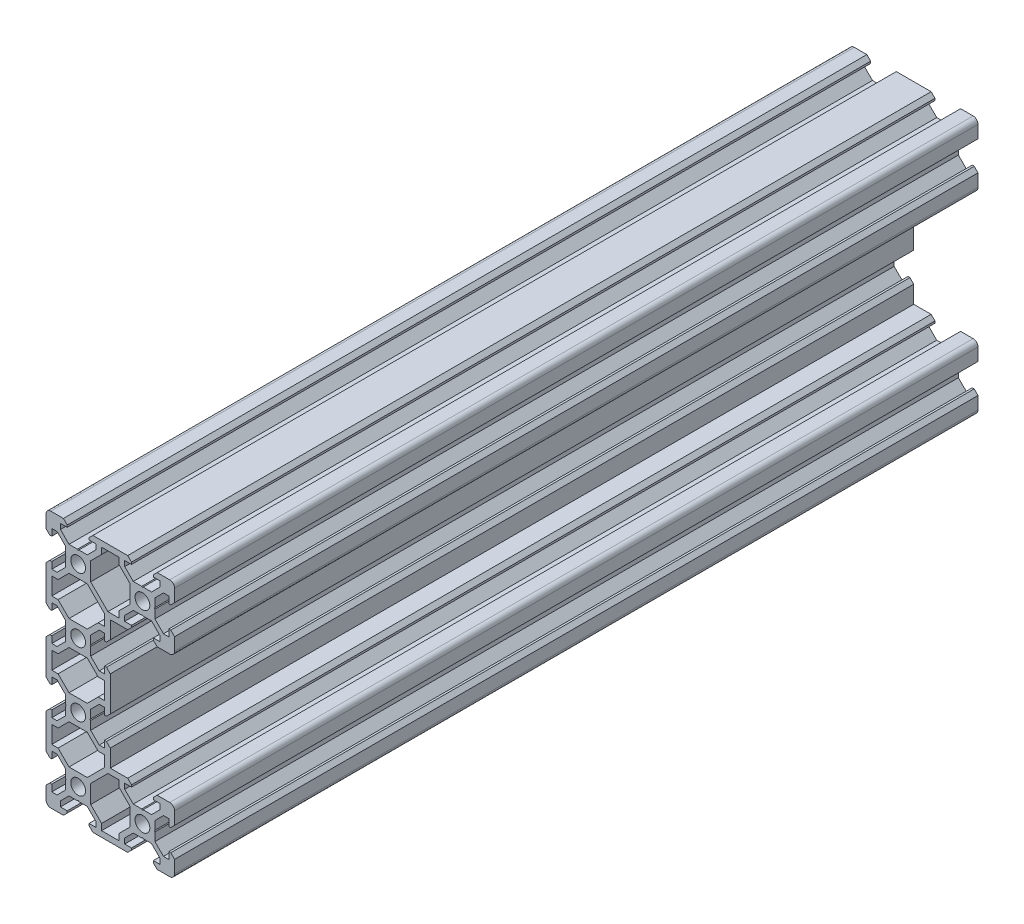
from build123d import *

# Parameters (mm, degrees)
SKETCH1_R           = 2.3
BOSS_EXTRUDE1_DEPTH = 250


with BuildPart() as part:
    # Sketch1 → Boss-Extrude1 (new body)
    with BuildSketch(Plane.XY):
        with BuildLine():
            Line((-20, -34.58), (-20, -38.5))
            ThreePointArc((-20, -38.5), (-19.560660172, -39.560660172), (-18.5, -40))
            Line((-18.5, -40), (-14.58, -40))
            Line((-14.58, -40), (-13.395, -38.815))
            Line((-13.395, -38.815), (-13.395, -38.2))
            Line((-13.395, -38.2), (-15.5, -38.2))
            Line((-15.5, -38.2), (-15.5, -36.560660172))
            Line((-15.5, -36.560660172), (-12.839339828, -33.9))
            Line((-12.839339828, -33.9), (-10.21, -33.9))
            Line((-10.21, -33.9), (-10, -33.69))
            Line((-10, -33.69), (-9.79, -33.9))
            Line((-9.79, -33.9), (-7.160660172, -33.9))
            Line((-7.160660172, -33.9), (-4.5, -36.560660172))
            Line((-4.5, -36.560660172), (-4.5, -38.2))
            Line((-4.5, -38.2), (-6.605, -38.2))
            Line((-6.605, -38.2), (-6.605, -38.815))
            Line((-6.605, -38.815), (-5.42, -40))
            Line((-5.42, -40), (5.42, -40))
            Line((5.42, -40), (6.605, -38.815))
            Line((6.605, -38.815), (6.605, -38.2))
            Line((6.605, -38.2), (4.5, -38.2))
            Line((4.5, -38.2), (4.5, -36.560660172))
            Line((4.5, -36.560660172), (7.160660172, -33.9))
            Line((7.160660172, -33.9), (9.79, -33.9))
            Line((9.79, -33.9), (10, -33.69))
            Line((10, -33.69), (10.21, -33.9))
            Line((10.21, -33.9), (12.839339828, -33.9))
            Line((12.839339828, -33.9), (15.5, -36.560660172))
            Line((15.5, -36.560660172), (15.5, -38.2))
            Line((15.5, -38.2), (13.395, -38.2))
            Line((13.395, -38.2), (13.395, -38.815))
            Line((13.395, -38.815), (14.58, -40))
            Line((14.58, -40), (18.5, -40))
            ThreePointArc((18.5, -40), (19.560660172, -39.560660172), (20, -38.5))
            Line((20, -38.5), (20, -34.58))
            Line((20, -34.58), (18.815, -33.395))
            Line((18.815, -33.395), (18.2, -33.395))
            Line((18.2, -33.395), (18.2, -35.5))
            Line((18.2, -35.5), (16.560660172, -35.5))
            Line((16.560660172, -35.5), (13.9, -32.839339828))
            Line((13.9, -32.839339828), (13.9, -30.21))
            Line((13.9, -30.21), (13.69, -30))
            Line((13.69, -30), (13.9, -29.79))
            Line((13.9, -29.79), (13.9, -27.160660172))
            Line((13.9, -27.160660172), (16.560660172, -24.5))
            Line((16.560660172, -24.5), (18.2, -24.5))
            Line((18.2, -24.5), (18.2, -26.605))
            Line((18.2, -26.605), (18.815, -26.605))
            Line((18.815, -26.605), (20, -25.42))
            Line((20, -25.42), (20, -21.5))
            ThreePointArc((20, -21.5), (19.560660172, -20.439339828), (18.5, -20))
            Line((18.5, -20), (14.58, -20))
            Line((14.58, -20), (13.395, -21.185))
            Line((13.395, -21.185), (13.395, -21.8))
            Line((13.395, -21.8), (15.5, -21.8))
            Line((15.5, -21.8), (15.5, -23.439339828))
            Line((15.5, -23.439339828), (12.839339828, -26.1))
            Line((12.839339828, -26.1), (10.21, -26.1))
            Line((10.21, -26.1), (10, -26.31))
            Line((10, -26.31), (9.79, -26.1))
            Line((9.79, -26.1), (7.160660172, -26.1))
            Line((7.160660172, -26.1), (4.5, -23.439339828))
            Line((4.5, -23.439339828), (4.5, -21.8))
            Line((4.5, -21.8), (6.605, -21.8))
            Line((6.605, -21.8), (6.605, -21.185))
            Line((6.605, -21.185), (5.42, -20))
            Line((5.42, -20), (0, -20))
            Line((0, -20), (0, -14.58))
            Line((0, -14.58), (-1.185, -13.395))
            Line((-1.185, -13.395), (-1.8, -13.395))
            Line((-1.8, -13.395), (-1.8, -15.5))
            Line((-1.8, -15.5), (-3.439339828, -15.5))
            Line((-3.439339828, -15.5), (-6.1, -12.839339828))
            Line((-6.1, -12.839339828), (-6.1, -10.21))
            Line((-6.1, -10.21), (-6.31, -10))
            Line((-6.31, -10), (-6.1, -9.79))
            Line((-6.1, -9.79), (-6.1, -7.160660172))
            Line((-6.1, -7.160660172), (-3.439339828, -4.5))
            Line((-3.439339828, -4.5), (-1.8, -4.5))
            Line((-1.8, -4.5), (-1.8, -6.605))
            Line((-1.8, -6.605), (-1.185, -6.605))
            Line((-1.185, -6.605), (0, -5.42))
            Line((0, -5.42), (0, 5.42))
            Line((0, 5.42), (-1.185, 6.605))
            Line((-1.185, 6.605), (-1.8, 6.605))
            Line((-1.8, 6.605), (-1.8, 4.5))
            Line((-1.8, 4.5), (-3.439339828, 4.5))
            Line((-3.439339828, 4.5), (-6.1, 7.160660172))
            Line((-6.1, 7.160660172), (-6.1, 9.79))
            Line((-6.1, 9.79), (-6.31, 10))
            Line((-6.31, 10), (-6.1, 10.21))
            Line((-6.1, 10.21), (-6.1, 12.839339828))
            Line((-6.1, 12.839339828), (-3.439339828, 15.5))
            Line((-3.439339828, 15.5), (-1.8, 15.5))
            Line((-1.8, 15.5), (-1.8, 13.395))
            Line((-1.8, 13.395), (-1.185, 13.395))
            Line((-1.185, 13.395), (0, 14.58))
            Line((0, 14.58), (0, 20))
            Line((0, 20), (5.42, 20))
            Line((5.42, 20), (6.605, 21.185))
            Line((6.605, 21.185), (6.605, 21.8))
            Line((6.605, 21.8), (4.5, 21.8))
            Line((4.5, 21.8), (4.5, 23.439339828))
            Line((4.5, 23.439339828), (7.160660172, 26.1))
            Line((7.160660172, 26.1), (9.79, 26.1))
            Line((9.79, 26.1), (10, 26.31))
            Line((10, 26.31), (10.21, 26.1))
            Line((10.21, 26.1), (12.839339828, 26.1))
            Line((12.839339828, 26.1), (15.5, 23.439339828))
            Line((15.5, 23.439339828), (15.5, 21.8))
            Line((15.5, 21.8), (13.395, 21.8))
            Line((13.395, 21.8), (13.395, 21.185))
            Line((13.395, 21.185), (14.58, 20))
            Line((14.58, 20), (18.5, 20))
            ThreePointArc((18.5, 20), (19.560660172, 20.439339828), (20, 21.5))
            Line((20, 21.5), (20, 25.42))
            Line((20, 25.42), (18.815, 26.605))
            Line((18.815, 26.605), (18.2, 26.605))
            Line((18.2, 26.605), (18.2, 24.5))
            Line((18.2, 24.5), (16.560660172, 24.5))
            Line((16.560660172, 24.5), (13.9, 27.160660172))
            Line((13.9, 27.160660172), (13.9, 29.79))
            Line((13.9, 29.79), (13.69, 30))
            Line((13.69, 30), (13.9, 30.21))
            Line((13.9, 30.21), (13.9, 32.839339828))
            Line((13.9, 32.839339828), (16.560660172, 35.5))
            Line((16.560660172, 35.5), (18.2, 35.5))
            Line((18.2, 35.5), (18.2, 33.395))
            Line((18.2, 33.395), (18.815, 33.395))
            Line((18.815, 33.395), (20, 34.58))
            Line((20, 34.58), (20, 38.5))
            ThreePointArc((20, 38.5), (19.560660172, 39.560660172), (18.5, 40))
            Line((18.5, 40), (14.58, 40))
            Line((14.58, 40), (13.395, 38.815))
            Line((13.395, 38.815), (13.395, 38.2))
            Line((13.395, 38.2), (15.5, 38.2))
            Line((15.5, 38.2), (15.5, 36.560660172))
            Line((15.5, 36.560660172), (12.839339828, 33.9))
            Line((12.839339828, 33.9), (10.21, 33.9))
            Line((10.21, 33.9), (10, 33.69))
            Line((10, 33.69), (9.79, 33.9))
            Line((9.79, 33.9), (7.160660172, 33.9))
            Line((7.160660172, 33.9), (4.5, 36.560660172))
            Line((4.5, 36.560660172), (4.5, 38.2))
            Line((4.5, 38.2), (6.605, 38.2))
            Line((6.605, 38.2), (6.605, 38.815))
            Line((6.605, 38.815), (5.42, 40))
            Line((5.42, 40), (-5.42, 40))
            Line((-5.42, 40), (-6.605, 38.815))
            Line((-6.605, 38.815), (-6.605, 38.2))
            Line((-6.605, 38.2), (-4.5, 38.2))
            Line((-4.5, 38.2), (-4.5, 36.560660172))
            Line((-4.5, 36.560660172), (-7.160660172, 33.9))
            Line((-7.160660172, 33.9), (-9.79, 33.9))
            Line((-9.79, 33.9), (-10, 33.69))
            Line((-10, 33.69), (-10.21, 33.9))
            Line((-10.21, 33.9), (-12.839339828, 33.9))
            Line((-12.839339828, 33.9), (-15.5, 36.560660172))
            Line((-15.5, 36.560660172), (-15.5, 38.2))
            Line((-15.5, 38.2), (-13.395, 38.2))
            Line((-13.395, 38.2), (-13.395, 38.815))
            Line((-13.395, 38.815), (-14.58, 40))
            Line((-14.58, 40), (-18.5, 40))
            ThreePointArc((-18.5, 40), (-19.560660172, 39.560660172), (-20, 38.5))
            Line((-20, 38.5), (-20, 34.58))
            Line((-20, 34.58), (-18.815, 33.395))
            Line((-18.815, 33.395), (-18.2, 33.395))
            Line((-18.2, 33.395), (-18.2, 35.5))
            Line((-18.2, 35.5), (-16.560660172, 35.5))
            Line((-16.560660172, 35.5), (-13.9, 32.839339828))
            Line((-13.9, 32.839339828), (-13.9, 30.21))
            Line((-13.9, 30.21), (-13.69, 30))
            Line((-13.69, 30), (-13.9, 29.79))
            Line((-13.9, 29.79), (-13.9, 27.160660172))
            Line((-13.9, 27.160660172), (-16.560660172, 24.5))
            Line((-16.560660172, 24.5), (-18.2, 24.5))
            Line((-18.2, 24.5), (-18.2, 26.605))
            Line((-18.2, 26.605), (-18.815, 26.605))
            Line((-18.815, 26.605), (-20, 25.42))
            Line((-20, 25.42), (-20, 14.58))
            Line((-20, 14.58), (-18.815, 13.395))
            Line((-18.815, 13.395), (-18.2, 13.395))
            Line((-18.2, 13.395), (-18.2, 15.5))
            Line((-18.2, 15.5), (-16.560660172, 15.5))
            Line((-16.560660172, 15.5), (-13.9, 12.839339828))
            Line((-13.9, 12.839339828), (-13.9, 10.21))
            Line((-13.9, 10.21), (-13.69, 10))
            Line((-13.69, 10), (-13.9, 9.79))
            Line((-13.9, 9.79), (-13.9, 7.160660172))
            Line((-13.9, 7.160660172), (-16.560660172, 4.5))
            Line((-16.560660172, 4.5), (-18.2, 4.5))
            Line((-18.2, 4.5), (-18.2, 6.605))
            Line((-18.2, 6.605), (-18.815, 6.605))
            Line((-18.815, 6.605), (-20, 5.42))
            Line((-20, 5.42), (-20, -5.42))
            Line((-20, -5.42), (-18.815, -6.605))
            Line((-18.815, -6.605), (-18.2, -6.605))
            Line((-18.2, -6.605), (-18.2, -4.5))
            Line((-18.2, -4.5), (-16.560660172, -4.5))
            Line((-16.560660172, -4.5), (-13.9, -7.160660172))
            Line((-13.9, -7.160660172), (-13.9, -9.79))
            Line((-13.9, -9.79), (-13.69, -10))
            Line((-13.69, -10), (-13.9, -10.21))
            Line((-13.9, -10.21), (-13.9, -12.839339828))
            Line((-13.9, -12.839339828), (-16.560660172, -15.5))
            Line((-16.560660172, -15.5), (-18.2, -15.5))
            Line((-18.2, -15.5), (-18.2, -13.395))
            Line((-18.2, -13.395), (-18.815, -13.395))
            Line((-18.815, -13.395), (-20, -14.58))
            Line((-20, -14.58), (-20, -25.42))
            Line((-20, -25.42), (-18.815, -26.605))
            Line((-18.815, -26.605), (-18.2, -26.605))
            Line((-18.2, -26.605), (-18.2, -24.5))
            Line((-18.2, -24.5), (-16.560660172, -24.5))
            Line((-16.560660172, -24.5), (-13.9, -27.160660172))
            Line((-13.9, -27.160660172), (-13.9, -29.79))
            Line((-13.9, -29.79), (-13.69, -30))
            Line((-13.69, -30), (-13.9, -30.21))
            Line((-13.9, -30.21), (-13.9, -32.839339828))
            Line((-13.9, -32.839339828), (-16.560660172, -35.5))
            Line((-16.560660172, -35.5), (-18.2, -35.5))
            Line((-18.2, -35.5), (-18.2, -33.395))
            Line((-18.2, -33.395), (-18.815, -33.395))
            Line((-18.815, -33.395), (-20, -34.58))
        make_face()
        with Locations((-10, -30)):
            Circle(SKETCH1_R, mode=Mode.SUBTRACT)
        Polygon((-16.239339828, -22.7), (-18.2, -22.7), (-18.2, -17.3), (-16.239339828, -17.3), (-12.839339828, -13.9), (-7.160660172, -13.9), (-3.760660172, -17.3), (-1.8, -17.3), (-1.8, -20.739339828), (-7.160660172, -26.1), (-12.839339828, -26.1), align=None, mode=Mode.SUBTRACT)
        with Locations((-10, -10)):
            Circle(SKETCH1_R, mode=Mode.SUBTRACT)
        Polygon((2.7, -36.239339828), (2.7, -38.2), (-2.7, -38.2), (-2.7, -36.239339828), (-6.1, -32.839339828), (-6.1, -27.160660172), (-0.739339828, -21.8), (2.7, -21.8), (2.7, -23.760660172), (6.1, -27.160660172), (6.1, -32.839339828), align=None, mode=Mode.SUBTRACT)
        with Locations((10, -30)):
            Circle(SKETCH1_R, mode=Mode.SUBTRACT)
        Polygon((-16.239339828, -2.7), (-18.2, -2.7), (-18.2, 2.7), (-16.239339828, 2.7), (-12.839339828, 6.1), (-7.160660172, 6.1), (-3.760660172, 2.7), (-1.8, 2.7), (-1.8, -2.7), (-3.760660172, -2.7), (-7.160660172, -6.1), (-12.839339828, -6.1), align=None, mode=Mode.SUBTRACT)
        with Locations((-10, 10)):
            Circle(SKETCH1_R, mode=Mode.SUBTRACT)
        Polygon((-16.239339828, 17.3), (-18.2, 17.3), (-18.2, 22.7), (-16.239339828, 22.7), (-12.839339828, 26.1), (-7.160660172, 26.1), (-1.8, 20.739339828), (-1.8, 17.3), (-3.760660172, 17.3), (-7.160660172, 13.9), (-12.839339828, 13.9), align=None, mode=Mode.SUBTRACT)
        with Locations((-10, 30)):
            Circle(SKETCH1_R, mode=Mode.SUBTRACT)
        Polygon((-2.7, 36.239339828), (-2.7, 38.2), (2.7, 38.2), (2.7, 36.239339828), (6.1, 32.839339828), (6.1, 27.160660172), (2.7, 23.760660172), (2.7, 21.8), (-0.739339828, 21.8), (-6.1, 27.160660172), (-6.1, 32.839339828), align=None, mode=Mode.SUBTRACT)
        with Locations((10, 30)):
            Circle(SKETCH1_R, mode=Mode.SUBTRACT)
    extrude(amount=BOSS_EXTRUDE1_DEPTH)


solid = part.part
